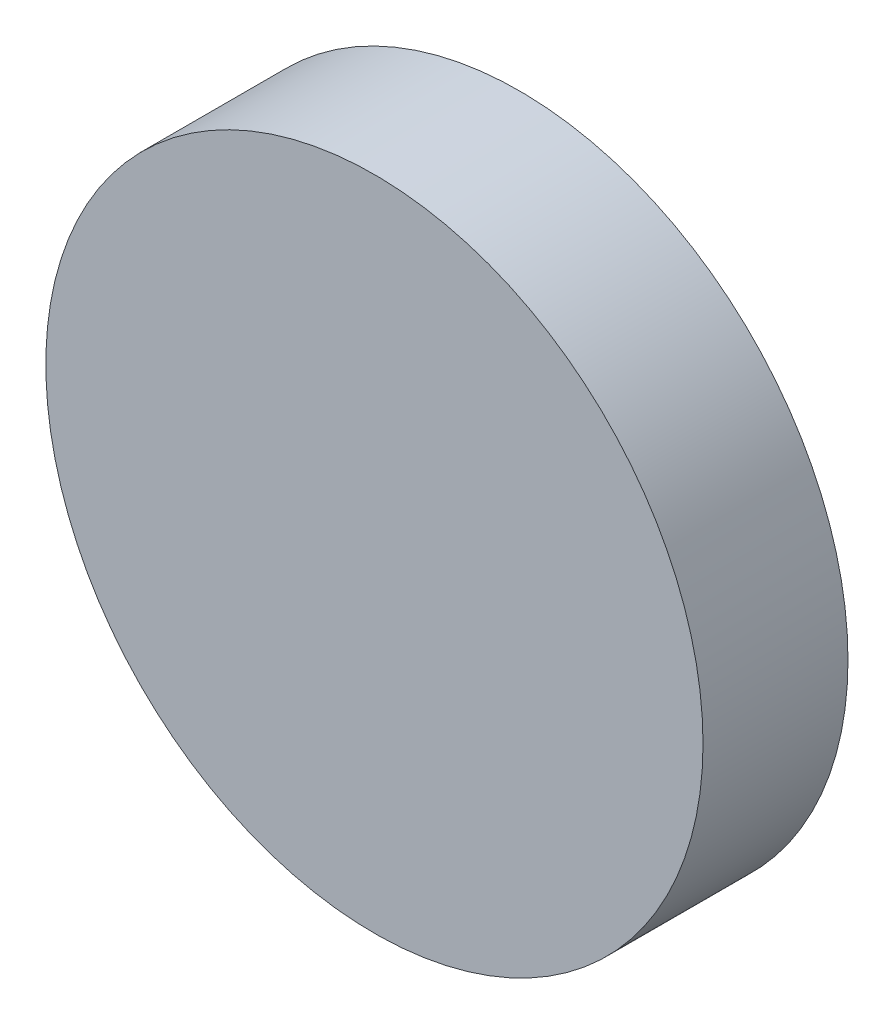
from build123d import *

# Parameters (mm, degrees)
CROQUIS1_R              = 2.04
SALIENTE_EXTRUIR1_DEPTH = 0.9


with BuildPart() as part:
    # Croquis1 → Saliente-Extruir1 (new body)
    with BuildSketch(Plane.XY):
        Circle(CROQUIS1_R)
    extrude(amount=SALIENTE_EXTRUIR1_DEPTH)


solid = part.part
